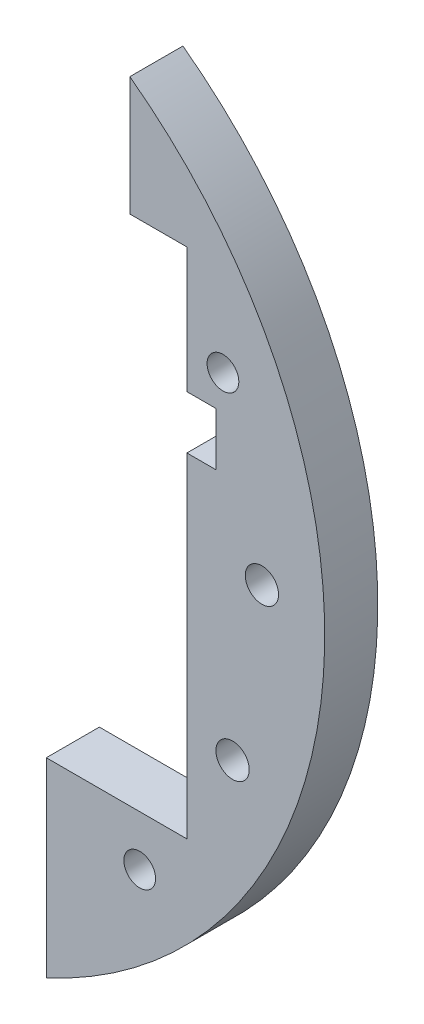
from build123d import *

# Parameters (mm, degrees)
SKETCH1_R           = 57.5
SKETCH1_R_2         = 1.89865
SKETCH1_R_3         = 1.9939
SKETCH1_R_4         = 8
BOSS_EXTRUDE1_DEPTH = 6.35
CUT_EXTRUDE1_DEPTH  = 82.564836173
SKETCH3_W           = 6.35
SKETCH3_H           = 80
CUT_EXTRUDE3_DEPTH  = 82.564836173
CUT_EXTRUDE5_DEPTH  = 82.564836173
CUT_EXTRUDE6_DEPTH  = 78.899883665


with BuildPart() as part:
    # Sketch1 → Boss-Extrude1 (new body)
    with BuildSketch(Plane.XY):
        Circle(SKETCH1_R)
        with Locations((45.315389352, 21.130913087)):
            Circle(SKETCH1_R_2, mode=Mode.SUBTRACT)
        with Locations((49.978847504, 1.454235937)):
            Circle(SKETCH1_R_3, mode=Mode.SUBTRACT)
        Circle(SKETCH1_R_4, mode=Mode.SUBTRACT)
        with Locations((46.467376211, -18.460307366)):
            Circle(SKETCH1_R_3, mode=Mode.SUBTRACT)
        with Locations((0, -16.5)):
            Circle(SKETCH1_R_3, mode=Mode.SUBTRACT)
        with Locations((0, -50)):
            Circle(SKETCH1_R_2, mode=Mode.SUBTRACT)
        with Locations((-16.5, 0)):
            Circle(SKETCH1_R_3, mode=Mode.SUBTRACT)
        with Locations((-11.66726189, -11.66726189)):
            Circle(SKETCH1_R_2, mode=Mode.SUBTRACT)
        with Locations((0, 16.5)):
            Circle(SKETCH1_R_3, mode=Mode.SUBTRACT)
        with Locations((-11.66726189, 11.66726189)):
            Circle(SKETCH1_R_2, mode=Mode.SUBTRACT)
        with Locations((11.66726189, 11.66726189)):
            Circle(SKETCH1_R_2, mode=Mode.SUBTRACT)
        with Locations((-35.355339059, -35.355339059)):
            Circle(SKETCH1_R_2, mode=Mode.SUBTRACT)
        with Locations((-50, 0)):
            Circle(SKETCH1_R_2, mode=Mode.SUBTRACT)
        with Locations((-35.355339059, 35.355339059)):
            Circle(SKETCH1_R_2, mode=Mode.SUBTRACT)
        with Locations((0, 50)):
            Circle(SKETCH1_R_2, mode=Mode.SUBTRACT)
        with Locations((35.355339059, -35.355339059)):
            Circle(SKETCH1_R_2, mode=Mode.SUBTRACT)
    extrude(amount=BOSS_EXTRUDE1_DEPTH)

    # Sketch2 → Cut-Extrude1 (cut, through all)
    with BuildSketch(Plane.XY):
        Polygon((12.5, -29.35), (41, -29.35), (41, 10.65), (44.5, 10.65), (44.5, 17), (41, 17), (41, 32), (21, 32), (21, 17), (17.5, 17), (17.5, 10.65), (21, 10.65), (21, 5.65), (12.5, 5.65), align=None)
    extrude(amount=CUT_EXTRUDE1_DEPTH, mode=Mode.SUBTRACT)

    # Sketch3 → Cut-Extrude3 (cut, through all)
    with BuildSketch(Plane(origin=(0, 0, 0), x_dir=(-1, 0, 0), z_dir=(0, 0, -1))):
        with Locations((-31, 32)):
            Rectangle(SKETCH3_W, SKETCH3_H)
    extrude(amount=-CUT_EXTRUDE3_DEPTH, mode=Mode.SUBTRACT)

    # Sketch4 → Cut-Extrude5 (cut, through all)
    with BuildSketch(Plane.XY):
        with BuildLine():
            Line((21, -36.500002949), (21, -5.372089924))
            Line((21, -5.372089924), (24.175, -5.411516926))
            Line((24.175, -5.411516926), (24.175, -57.5))
            Line((24.175, -57.5), (2.949e-06, -57.5))
            ThreePointArc((2.949e-06, -57.5), (14.849243269, -51.349243269), (21, -36.500002949))
        make_face()
        with BuildLine():
            Line((2.949e-06, 57.5), (24.175, 57.5))
            Line((24.175, 57.5), (24.175, 5.411516926))
            Line((24.175, 5.411516926), (21, 5.372089924))
            Line((21, 5.372089924), (21, 36.500002949))
            ThreePointArc((21, 36.500002949), (14.849243269, 51.349243269), (2.949e-06, 57.5))
        make_face()
    extrude(amount=CUT_EXTRUDE5_DEPTH, mode=Mode.SUBTRACT)


with BuildPart() as cut_extrude5_piece_1:
    # of the separate pieces the step leaves, piece 1, a body of its own (cut_extrude5_pieces_kept)
    add(part.part.solids().sort_by_distance((24.175, -52.171058787, 0))[0])


with BuildPart() as cut_extrude5_piece_2:
    # of the separate pieces the step leaves, piece 2, a body of its own (cut_extrude5_pieces_kept)
    add(part.part.solids().sort_by_distance((24.175, 52.171058787, 6.35))[0])

    # Sketch5 → Cut-Extrude6 (cut, through all)
    with BuildSketch(Plane.XY.offset(6.35)):
        with BuildLine():
            Line((24.175, 52.171058787), (24.175, 32))
            Line((24.175, 32), (27.825, 32))
            Line((27.825, 32), (27.825, 50.319175023))
            ThreePointArc((27.825, 50.319175023), (26.016482629, 51.277603607), (24.175, 52.171058787))
        make_face()
    extrude(amount=-CUT_EXTRUDE6_DEPTH, mode=Mode.SUBTRACT)


solid = cut_extrude5_piece_1.part
